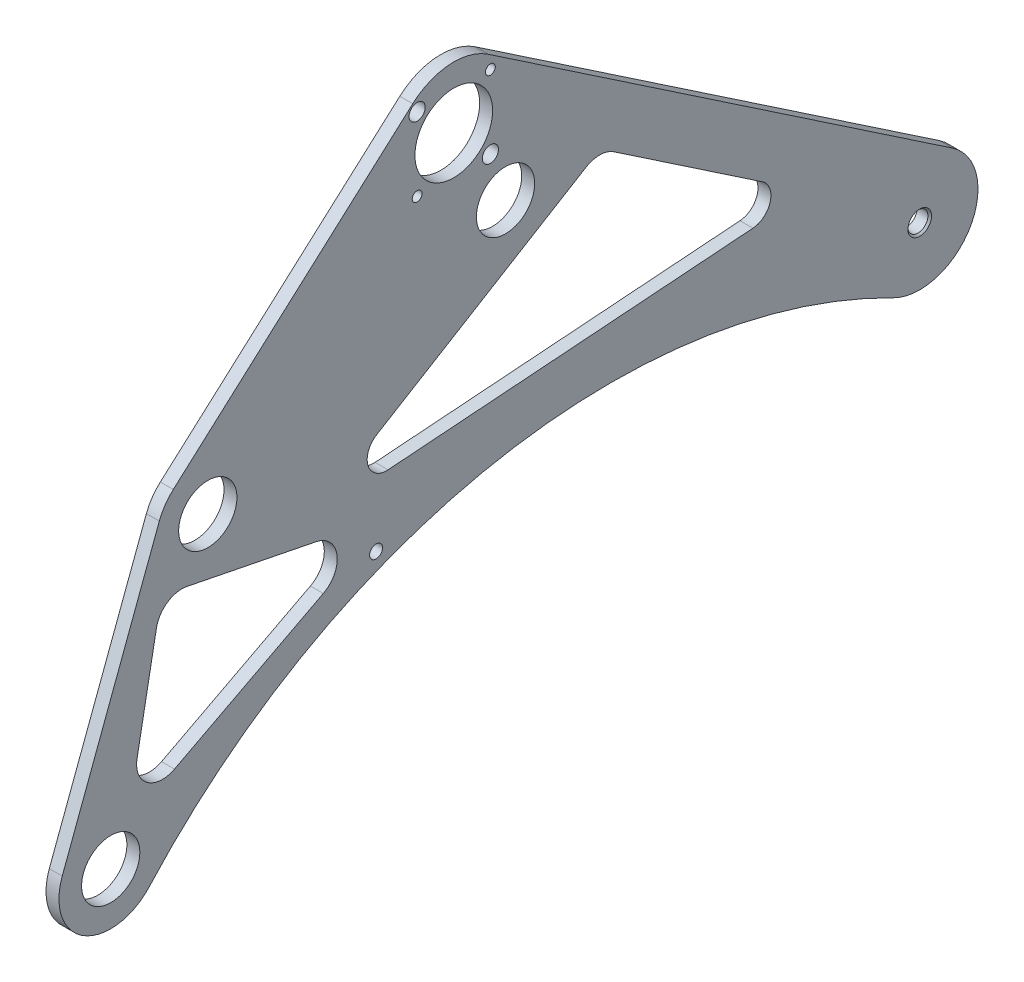
from build123d import *

# Parameters (mm, degrees)
BOSS_EXTRUDE1_DEPTH               = 6.35
CUT_EXTRUDE1_REACH                = 8.35
SKETCH3_R                         = 14.2875
SKETCH3_R_2                       = 19.05
SKETCH3_R_3                       = 2.413
SKETCH3_R_4                       = 3.96875
F_3_8_CLEARANCE_HOLE2_D           = 9.8044
F_3_8_CLEARANCE_HOLE2_CSINK_D     = 11.58748
F_3_8_CLEARANCE_HOLE2_CSINK_ANGLE = 90
F_1_4_0_2500_DOWEL_HOLE2_D        = 6.35
CUT_EXTRUDE2_DEPTH                = 7.35


with BuildPart() as part:
    # Sketch2 → Boss-Extrude1 (new body)
    with BuildSketch(Plane(origin=(0, 0, 0), x_dir=(0, 0, -1), z_dir=(1, 0, 0))):
        with BuildLine():
            Line((-420.65776111, -67.281464584), (-373.03276111, 59.718535416))
            ThreePointArc((-373.03276111, 59.718535416), (-370.217283815, 65.136422477), (-366.190217158, 69.725882876))
            Line((-366.190217158, 69.725882876), (-248.716507876, 174.874485915))
            ThreePointArc((-248.716507876, 174.874485915), (-230.65414247, 182.492472563), (-211.724122614, 177.399623371))
            Line((-211.724122614, 177.399623371), (15.987673313, 23.68385372))
            ThreePointArc((15.987673313, 23.68385372), (24.617664495, -14.508660165), (-12.975284095, -25.459234624))
            ThreePointArc((-12.975284095, -25.459234624), (-206.983757432, 2.660555148), (-377.990639572, -93.186492612))
            ThreePointArc((-377.990639572, -93.186492612), (-410.057040874, -97.911605155), (-420.65776111, -67.281464584))
        make_face()
    extrude(amount=BOSS_EXTRUDE1_DEPTH)

    # Sketch3 → Cut-Extrude1 (cut, up to next)
    with BuildSketch(Plane(origin=(6.35, 0, 0), x_dir=(0, 0, -1), z_dir=(1, 0, 0)), mode=Mode.PRIVATE) as cut_extrude1_sk1:
        with Locations((-203.2, 111.125)):
            Circle(SKETCH3_R)
    cut_extrude1_tool1 = extrude(cut_extrude1_sk1.sketch, amount=-CUT_EXTRUDE1_REACH, mode=Mode.PRIVATE) & part.part
    add(cut_extrude1_tool1.solids().sort_by_distance((6.35, 111.125, 203.2))[0], mode=Mode.SUBTRACT)
    # Sketch3 → Cut-Extrude1 (cut, up to next)
    with BuildSketch(Plane(origin=(6.35, 0, 0), x_dir=(0, 0, -1), z_dir=(1, 0, 0)), mode=Mode.PRIVATE) as cut_extrude1_sk2:
        with Locations((-349.25, 50.8)):
            Circle(SKETCH3_R)
    cut_extrude1_tool2 = extrude(cut_extrude1_sk2.sketch, amount=-CUT_EXTRUDE1_REACH, mode=Mode.PRIVATE) & part.part
    add(cut_extrude1_tool2.solids().sort_by_distance((6.35, 50.8, 349.25))[0], mode=Mode.SUBTRACT)
    # Sketch3 → Cut-Extrude1 (cut, up to next)
    with BuildSketch(Plane(origin=(6.35, 0, 0), x_dir=(0, 0, -1), z_dir=(1, 0, 0)), mode=Mode.PRIVATE) as cut_extrude1_sk3:
        with Locations((-396.875, -76.2)):
            Circle(SKETCH3_R)
    cut_extrude1_tool3 = extrude(cut_extrude1_sk3.sketch, amount=-CUT_EXTRUDE1_REACH, mode=Mode.PRIVATE) & part.part
    add(cut_extrude1_tool3.solids().sort_by_distance((6.35, -76.2, 396.875))[0], mode=Mode.SUBTRACT)
    # Sketch3 → Cut-Extrude1 (cut, up to next)
    with BuildSketch(Plane(origin=(6.35, 0, 0), x_dir=(0, 0, -1), z_dir=(1, 0, 0)), mode=Mode.PRIVATE) as cut_extrude1_sk4:
        with Locations((-228.6, 152.4)):
            Circle(SKETCH3_R_2)
    cut_extrude1_tool4 = extrude(cut_extrude1_sk4.sketch, amount=-CUT_EXTRUDE1_REACH, mode=Mode.PRIVATE) & part.part
    add(cut_extrude1_tool4.solids().sort_by_distance((6.35, 152.4, 228.6))[0], mode=Mode.SUBTRACT)
    # Sketch3 → Cut-Extrude1 (cut, up to next)
    with BuildSketch(Plane(origin=(6.35, 0, 0), x_dir=(0, 0, -1), z_dir=(1, 0, 0)), mode=Mode.PRIVATE) as cut_extrude1_sk5:
        with Locations((-246.560512242, 134.439487758)):
            Circle(SKETCH3_R_3)
    cut_extrude1_tool5 = extrude(cut_extrude1_sk5.sketch, amount=-CUT_EXTRUDE1_REACH, mode=Mode.PRIVATE) & part.part
    add(cut_extrude1_tool5.solids().sort_by_distance((6.35, 134.439488, 246.560512))[0], mode=Mode.SUBTRACT)
    # Sketch3 → Cut-Extrude1 (cut, up to next)
    with BuildSketch(Plane(origin=(6.35, 0, 0), x_dir=(0, 0, -1), z_dir=(1, 0, 0)), mode=Mode.PRIVATE) as cut_extrude1_sk6:
        with Locations((-210.639487758, 134.439487758)):
            Circle(SKETCH3_R_4)
    cut_extrude1_tool6 = extrude(cut_extrude1_sk6.sketch, amount=-CUT_EXTRUDE1_REACH, mode=Mode.PRIVATE) & part.part
    add(cut_extrude1_tool6.solids().sort_by_distance((6.35, 134.439488, 210.639488))[0], mode=Mode.SUBTRACT)
    # Sketch3 → Cut-Extrude1 (cut, up to next)
    with BuildSketch(Plane(origin=(6.35, 0, 0), x_dir=(0, 0, -1), z_dir=(1, 0, 0)), mode=Mode.PRIVATE) as cut_extrude1_sk7:
        with Locations((-210.639487758, 170.360512242)):
            Circle(SKETCH3_R_3)
    cut_extrude1_tool7 = extrude(cut_extrude1_sk7.sketch, amount=-CUT_EXTRUDE1_REACH, mode=Mode.PRIVATE) & part.part
    add(cut_extrude1_tool7.solids().sort_by_distance((6.35, 170.360512, 210.639488))[0], mode=Mode.SUBTRACT)
    # Sketch3 → Cut-Extrude1 (cut, up to next)
    with BuildSketch(Plane(origin=(6.35, 0, 0), x_dir=(0, 0, -1), z_dir=(1, 0, 0)), mode=Mode.PRIVATE) as cut_extrude1_sk8:
        with Locations((-246.560512242, 170.360512242)):
            Circle(SKETCH3_R_4)
    cut_extrude1_tool8 = extrude(cut_extrude1_sk8.sketch, amount=-CUT_EXTRUDE1_REACH, mode=Mode.PRIVATE) & part.part
    add(cut_extrude1_tool8.solids().sort_by_distance((6.35, 170.360512, 246.560512))[0], mode=Mode.SUBTRACT)

    # 3/8 Clearance Hole2 (through all)
    with Locations(Plane(origin=(6.35, 0, 0), x_dir=(0, 0, -1), z_dir=(1, 0, 0))):
        with Locations((0, 0)):
            CounterSinkHole(F_3_8_CLEARANCE_HOLE2_D / 2, F_3_8_CLEARANCE_HOLE2_CSINK_D / 2, counter_sink_angle=F_3_8_CLEARANCE_HOLE2_CSINK_ANGLE)

    # 1/4 (0.2500) Dowel Hole2 (through all)
    with Locations(Plane(origin=(6.35, 0, 0), x_dir=(0, 0, -1), z_dir=(1, 0, 0))):
        with Locations((-266.7, -6.35)):
            Hole(F_1_4_0_2500_DOWEL_HOLE2_D / 2)

    # Sketch14 → Cut-Extrude2 (cut, through all)
    with BuildSketch(Plane(origin=(6.35, 0, 0), x_dir=(0, 0, -1), z_dir=(1, 0, 0))):
        with BuildLine():
            Line((-365.600411715, -49.359627546), (-292.575411715, -11.259627546))
            ThreePointArc((-292.575411715, -11.259627546), (-285.877370021, 1.794150333), (-295.959325084, 12.453374581))
            Line((-295.959325084, 12.453374581), (-359.459325084, 25.153374581))
            ThreePointArc((-359.459325084, 25.153374581), (-369.058218075, 23.224411423), (-374.432476774, 15.040464395))
            Line((-374.432476774, 15.040464395), (-383.957476774, -35.759535605))
            ThreePointArc((-383.957476774, -35.759535605), (-379.035203223, -48.304573838), (-365.600411715, -49.359627546))
        make_face()
        with BuildLine():
            Line((-77.20752162, 55.949267111), (-149.968519497, 105.066234213))
            ThreePointArc((-149.968519497, 105.066234213), (-156.765517001, 107.236326229), (-163.659929975, 105.39906082))
            Line((-163.659929975, 105.39906082), (-266.47492871, 43.043617869))
            ThreePointArc((-266.47492871, 43.043617869), (-270.608700361, 32.000347521), (-260.837451688, 25.4))
            Line((-260.837451688, 25.4), (-81.838602457, 38.555269198))
            ThreePointArc((-81.838602457, 38.555269198), (-73.332394792, 45.604028308), (-77.20752162, 55.949267111))
        make_face()
    extrude(amount=-CUT_EXTRUDE2_DEPTH, mode=Mode.SUBTRACT)


solid = part.part
